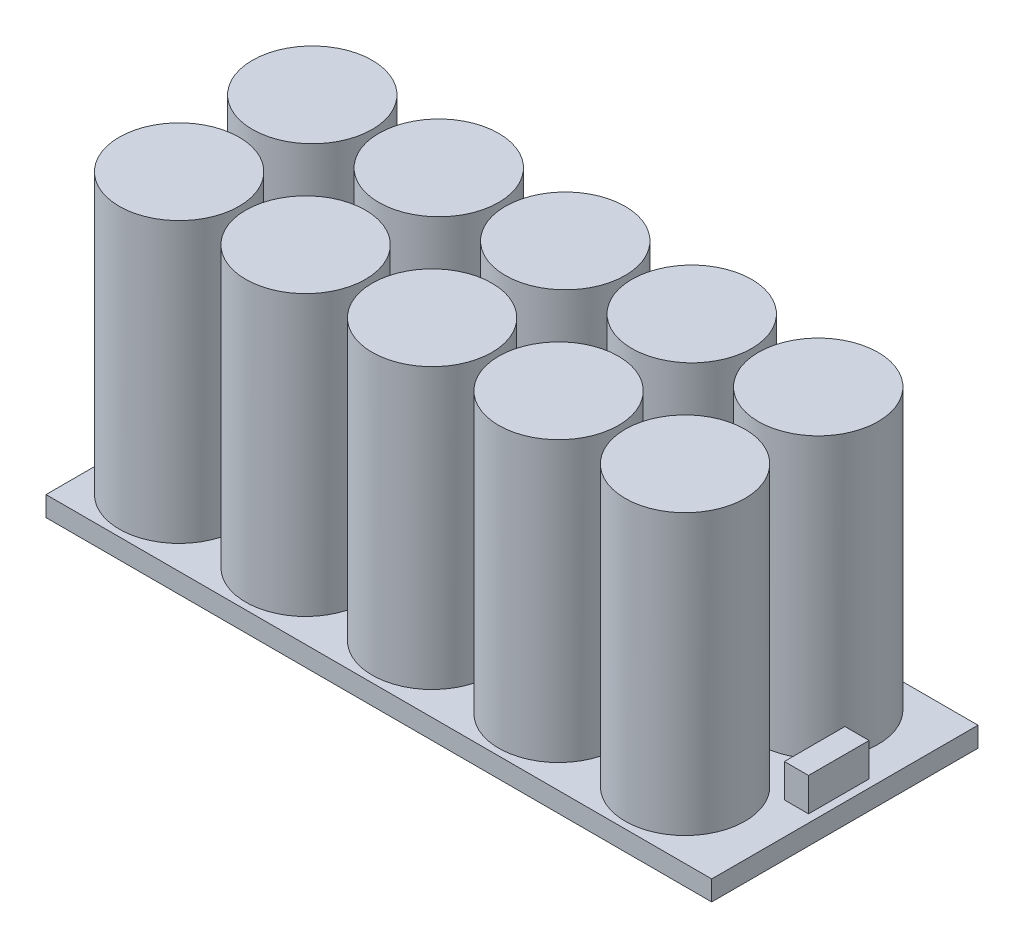
from build123d import *

# Parameters (mm, degrees)
SKETCH_1_W      = 100
SKETCH_1_H      = 40
EXTRUDE_2_DEPTH = 3
SKETCH_2_R      = 9
EXTRUDE_3_DEPTH = 42
SKETCH_3_W      = 3.629615038
SKETCH_3_H      = 9.091657085
EXTRUDE_4_DEPTH = 5


with BuildPart() as part:
    # 草图1 → 凸台-拉伸2 (new body)
    with BuildSketch(Plane(origin=(0, 0, 0), x_dir=(1, 0, 0), z_dir=(0, 1, 0))):
        Rectangle(SKETCH_1_W, SKETCH_1_H)
    extrude(amount=EXTRUDE_2_DEPTH)

    # 草图2 → 凸台-拉伸3 (add)
    with BuildSketch(Plane(origin=(0, 3, 0), x_dir=(1, 0, 0), z_dir=(0, 1, 0))):
        with Locations((-40, -10)):
            Circle(SKETCH_2_R)
        with Locations((-21, -10)):
            Circle(SKETCH_2_R)
        with Locations((-2, -10)):
            Circle(SKETCH_2_R)
        with Locations((17, -10)):
            Circle(SKETCH_2_R)
        with Locations((36, -10)):
            Circle(SKETCH_2_R)
        with Locations((-21, 10)):
            Circle(SKETCH_2_R)
        with Locations((-2, 10)):
            Circle(SKETCH_2_R)
        with Locations((17, 10)):
            Circle(SKETCH_2_R)
        with Locations((36, 10)):
            Circle(SKETCH_2_R)
        with Locations((-40, 10)):
            Circle(SKETCH_2_R)
    extrude(amount=EXTRUDE_3_DEPTH)

    # 草图3 → 凸台-拉伸4 (add)
    with BuildSketch(Plane(origin=(0, 3, 0), x_dir=(1, 0, 0), z_dir=(0, 1, 0))):
        with Locations((46.996489689, 0.280393631)):
            Rectangle(SKETCH_3_W, SKETCH_3_H)
    extrude(amount=EXTRUDE_4_DEPTH)


solid = part.part
